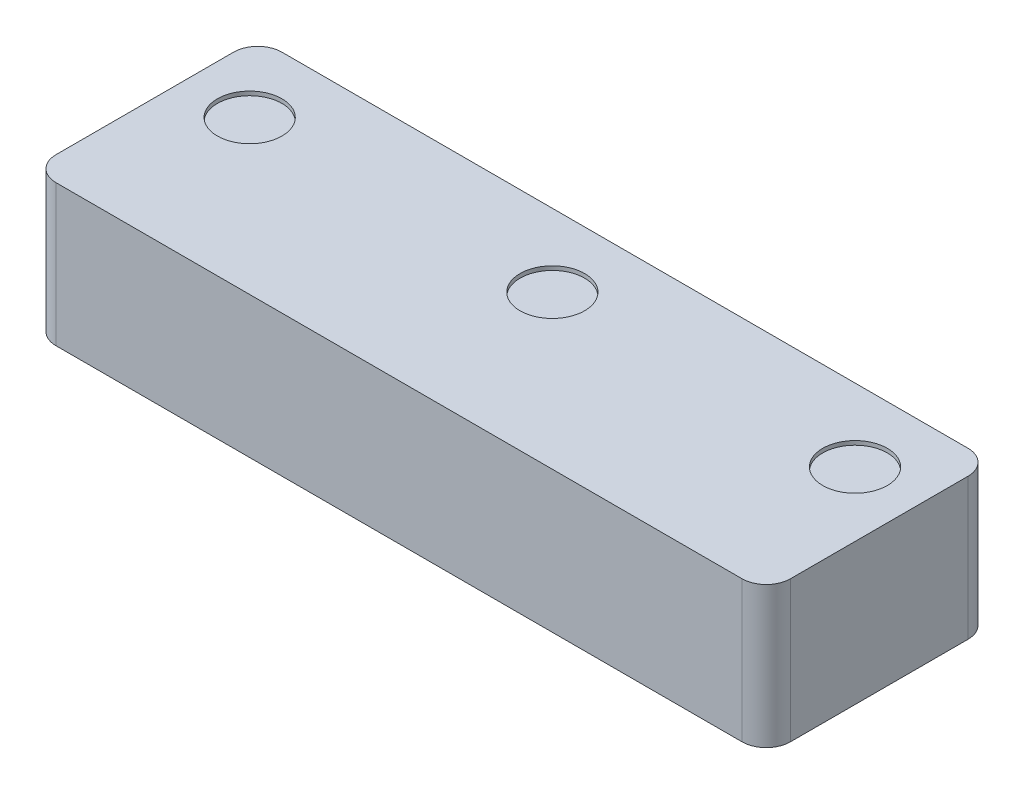
from build123d import *

# Parameters (mm, degrees)
SKETCH1_W           = 91
SKETCH1_H           = 28
BOSS_EXTRUDE1_DEPTH = 17.5
SKETCH2_R           = 4
CUT_EXTRUDE1_DEPTH  = 0.5
SKETCH3_R           = 2
CUT_EXTRUDE2_DEPTH  = 6.5
FILLET1_R           = 3


with BuildPart() as part:
    # Sketch1 → Boss-Extrude1 (new body)
    with BuildSketch(Plane(origin=(0, 0, 0), x_dir=(1, 0, 0), z_dir=(0, 1, 0))):
        with Locations((45.5, 14)):
            Rectangle(SKETCH1_W, SKETCH1_H)
    extrude(amount=BOSS_EXTRUDE1_DEPTH)

    # Sketch2 → Cut-Extrude1 (cut)
    with BuildSketch(Plane(origin=(0, 17.5, 0), x_dir=(1, 0, 0), z_dir=(0, 1, 0))):
        with Locations((45.5, 19)):
            Circle(SKETCH2_R)
        with Locations((8, 19)):
            Circle(SKETCH2_R)
        with Locations((83, 19)):
            Circle(SKETCH2_R)
    extrude(amount=-CUT_EXTRUDE1_DEPTH, mode=Mode.SUBTRACT)

    # Sketch3 → Cut-Extrude2 (cut)
    with BuildSketch(Plane.XZ):
        with Locations((83, -18.5)):
            Circle(SKETCH3_R)
        with Locations((8, -18.5)):
            Circle(SKETCH3_R)
    extrude(amount=-CUT_EXTRUDE2_DEPTH, mode=Mode.SUBTRACT)

    # Fillet1
    fillet1_edges = [part.edges().sort_by_distance(p)[0] for p in [
        (0, 8.75, -28),
        (91, 8.75, -28),
        (91, 8.75, 0),
        (0, 8.75, 0),
    ]]
    fillet(fillet1_edges, radius=FILLET1_R)


solid = part.part
